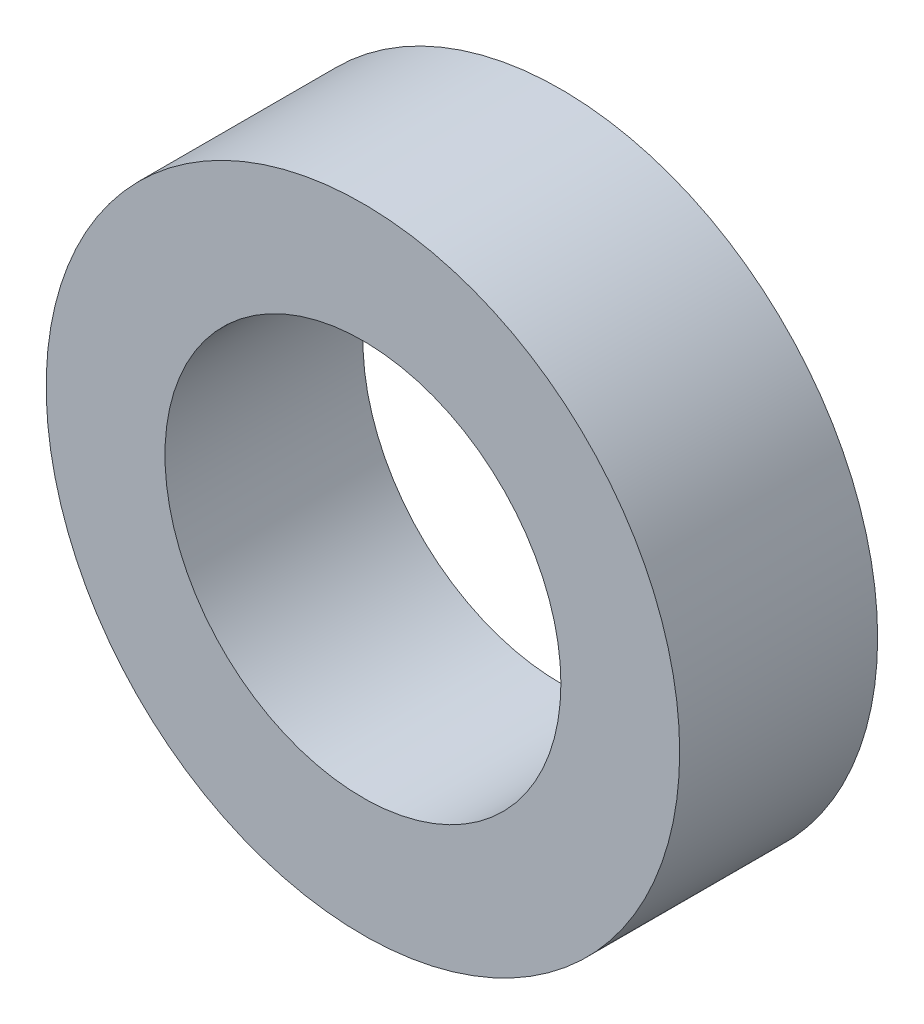
from build123d import *

# Parameters (mm, degrees)
SKETCH_1_R      = 4
SKETCH_1_R_2    = 2.5
EXTRUDE_1_DEPTH = 2.5


with BuildPart() as part:
    # 草图1 → 凸台-拉伸1 (new body)
    with BuildSketch(Plane.XY):
        Circle(SKETCH_1_R)
        Circle(SKETCH_1_R_2, mode=Mode.SUBTRACT)
    extrude(amount=EXTRUDE_1_DEPTH)


solid = part.part
